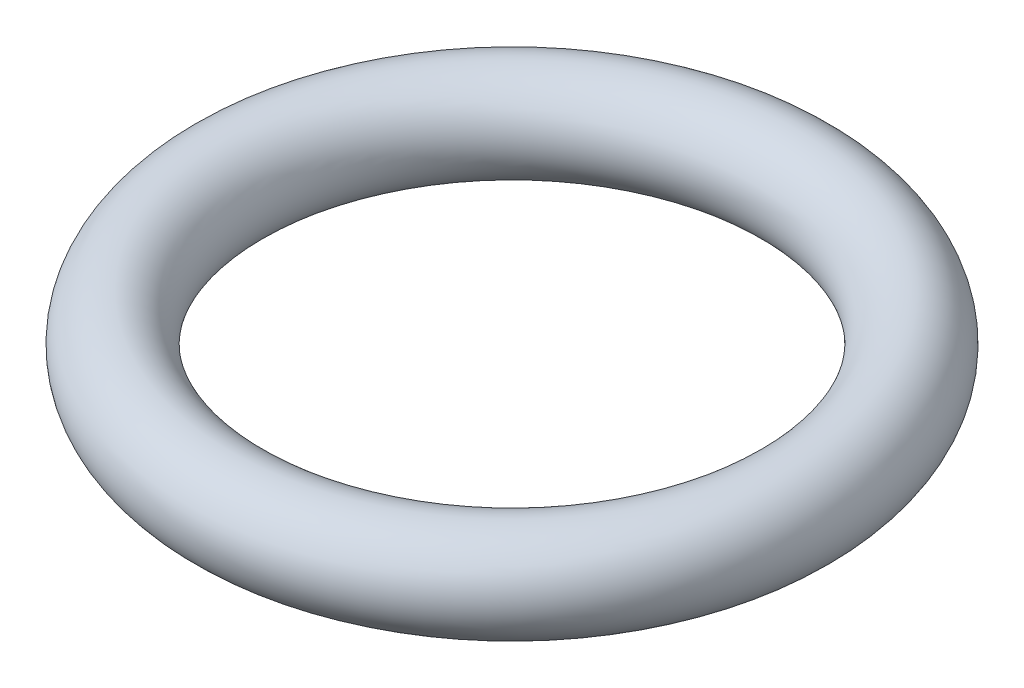
from build123d import *

# Parameters (mm, degrees)
SKETCH2_R = 25.4


with BuildPart() as part:
    # Sweep1: sweep along a path in Sketch1
    with BuildLine(Plane(origin=(0, 0, 0), x_dir=(1, 0, 0), z_dir=(0, 1, 0))) as sweep1_path:
        CenterArc((0, 0), 152.4, 0, 360)
    # Sketch2 → Sweep1 (sweep)
    with BuildSketch(Plane.XY):
        with Locations((-152.4, 0)):
            Circle(SKETCH2_R)
    sweep(path=sweep1_path.line)


solid = part.part
